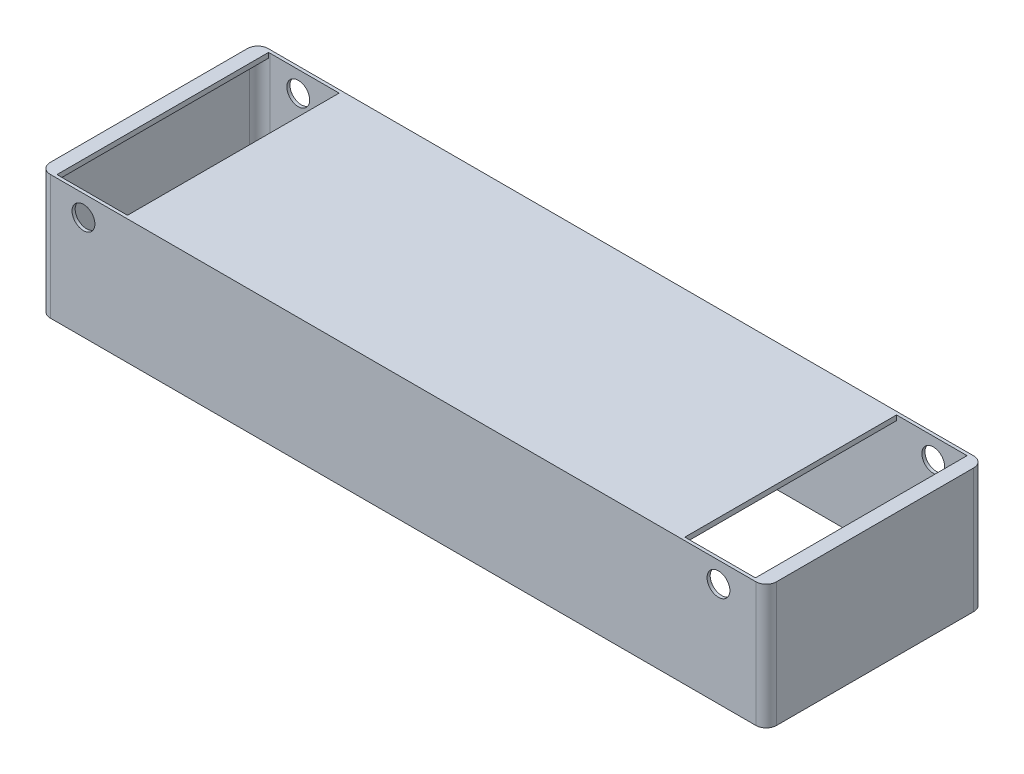
from build123d import *

# Parameters (mm, degrees)
SALIENTE_EXTRUIR1_DEPTH = 60
CROQUIS3_W              = 268.6
CROQUIS3_H              = 105
SALIENTE_EXTRUIR4_DEPTH = 2.4
CROQUIS4_R              = 5.5
CORTAR_EXTRUIR1_DEPTH   = 106


with BuildPart() as part:
    # Croquis2 → Saliente-Extruir1 (new body)
    with BuildSketch(Plane(origin=(0, 0, 0), x_dir=(1, 0, 0), z_dir=(0, 1, 0))):
        with BuildLine():
            Line((-170, 52.5), (170, 52.5))
            ThreePointArc((170, 52.5), (173.535533906, 51.035533906), (175, 47.5))
            Line((175, 47.5), (175, -47.5))
            ThreePointArc((175, -47.5), (173.535533906, -51.035533906), (170, -52.5))
            Line((170, -52.5), (-170, -52.5))
            ThreePointArc((-170, -52.5), (-173.535533906, -51.035533906), (-175, -47.5))
            Line((-175, -47.5), (-175, 47.5))
            ThreePointArc((-175, 47.5), (-173.535533906, 51.035533906), (-170, 52.5))
        make_face()
        with BuildLine():
            Line((-167.6, 51), (167.6, 51))
            ThreePointArc((167.6, 51), (171.135533906, 49.535533906), (172.6, 46))
            Line((172.6, 46), (172.6, -46))
            ThreePointArc((172.6, -46), (171.135533906, -49.535533906), (167.6, -51))
            Line((167.6, -51), (-167.6, -51))
            ThreePointArc((-167.6, -51), (-171.135533906, -49.535533906), (-172.6, -46))
            Line((-172.6, -46), (-172.6, 46))
            ThreePointArc((-172.6, 46), (-171.135533906, 49.535533906), (-167.6, 51))
        make_face(mode=Mode.SUBTRACT)
    extrude(amount=SALIENTE_EXTRUIR1_DEPTH)

    # Croquis3 → Saliente-Extruir4 (add)
    with BuildSketch(Plane(origin=(0, 60, 0), x_dir=(1, 0, 0), z_dir=(0, 1, 0))):
        with BuildLine():
            Line((-170, 52.5), (-168.3, 52.5))
            Line((-168.3, 52.5), (-168.3, -52.5))
            Line((-168.3, -52.5), (-170, -52.5))
            ThreePointArc((-170, -52.5), (-173.535533906, -51.035533906), (-175, -47.5))
            Line((-175, -47.5), (-175, 47.5))
            ThreePointArc((-175, 47.5), (-173.535533906, 51.035533906), (-170, 52.5))
        make_face()
        with BuildLine():
            Line((170, 52.5), (168.3, 52.5))
            Line((168.3, 52.5), (168.3, -52.5))
            Line((168.3, -52.5), (170, -52.5))
            ThreePointArc((170, -52.5), (173.535533906, -51.035533906), (175, -47.5))
            Line((175, -47.5), (175, 47.5))
            ThreePointArc((175, 47.5), (173.535533906, 51.035533906), (170, 52.5))
        make_face()
        Rectangle(CROQUIS3_W, CROQUIS3_H)
    extrude(amount=-SALIENTE_EXTRUIR4_DEPTH)

    # Croquis4 → Cortar-Extruir1 (cut, through all)
    with BuildSketch(Plane.XY.offset(52.5)):
        with Locations((152, 50)):
            Circle(CROQUIS4_R)
        with Locations((-154, 50)):
            Circle(CROQUIS4_R)
    extrude(amount=-CORTAR_EXTRUIR1_DEPTH, mode=Mode.SUBTRACT)


solid = part.part
